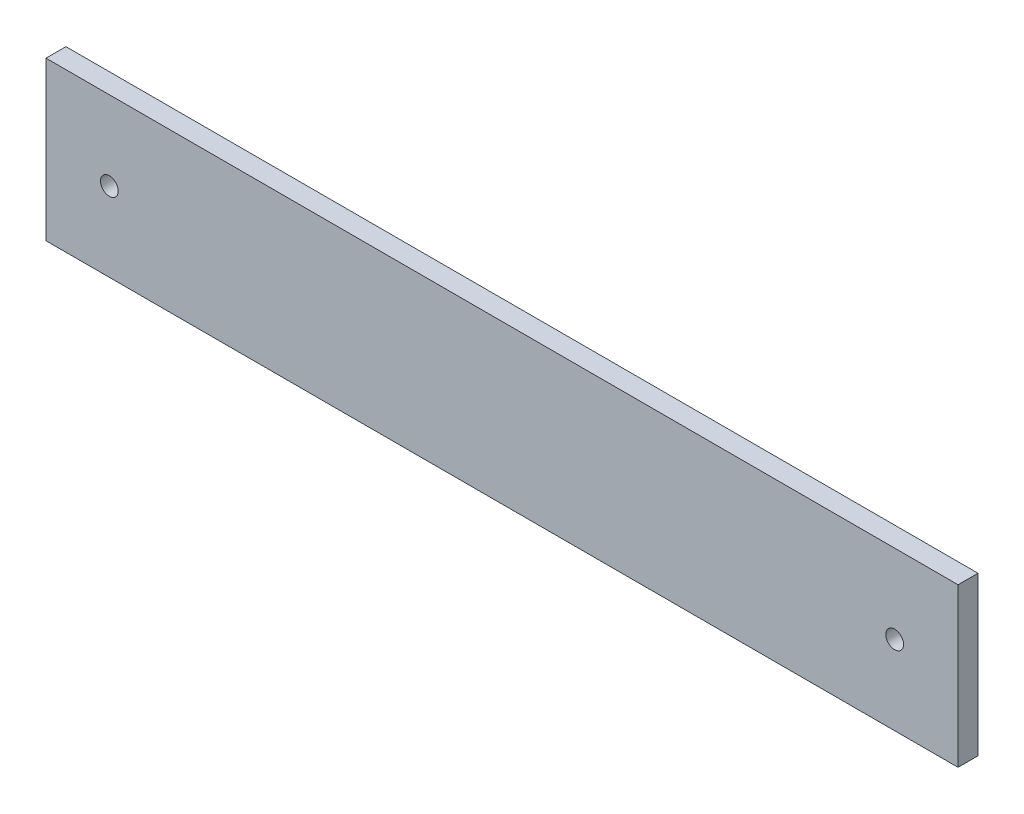
from build123d import *

# Parameters (mm, degrees)
SKETCH1_W           = 145.17
SKETCH1_H           = 25.172266624
SKETCH1_R           = 1.415
BOSS_EXTRUDE1_DEPTH = 3.175


with BuildPart() as part:
    # Sketch1 → Boss-Extrude1 (new body)
    with BuildSketch(Plane.XY):
        with Locations((-10.432378898, 12.498888975)):
            Rectangle(SKETCH1_W, SKETCH1_H)
        with Locations((-72.935280805, 12.5)):
            Circle(SKETCH1_R, mode=Mode.SUBTRACT)
        with Locations((52.064719195, 12.5)):
            Circle(SKETCH1_R, mode=Mode.SUBTRACT)
    extrude(amount=BOSS_EXTRUDE1_DEPTH)


solid = part.part
